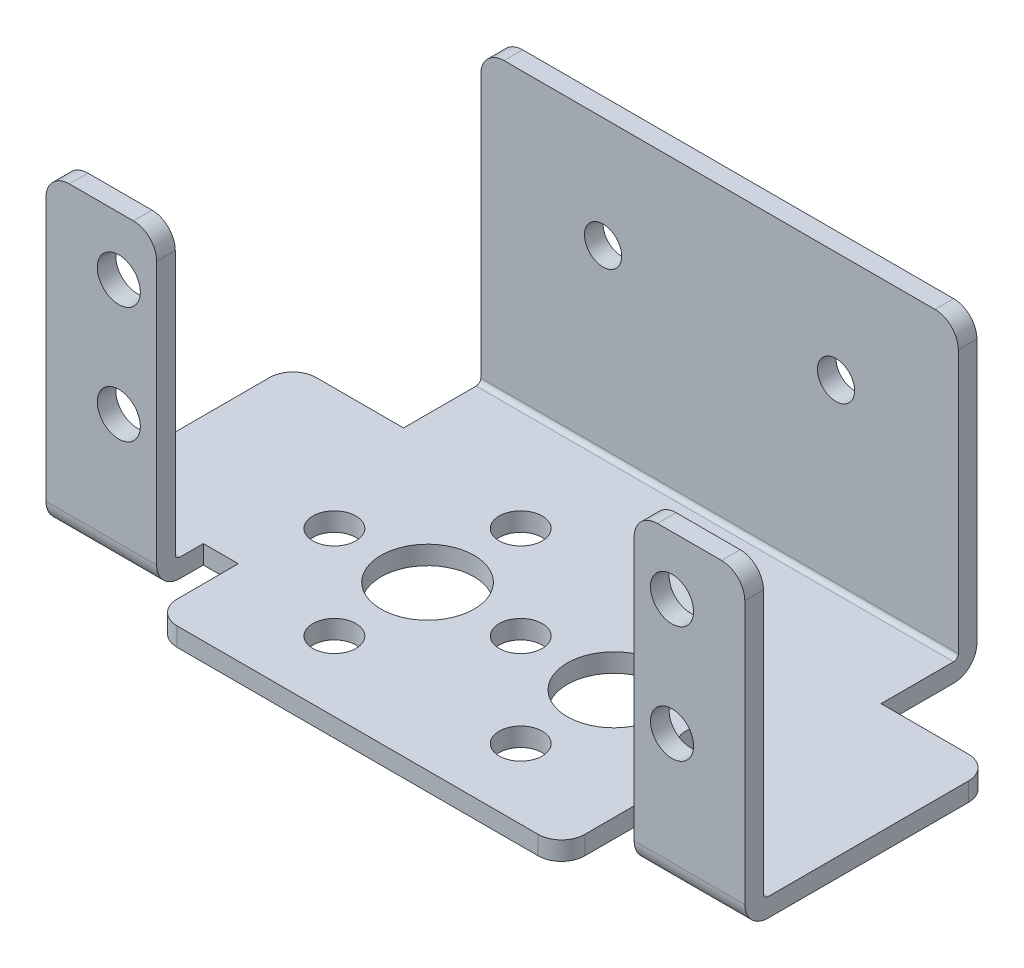
from build123d import *

# Parameters (mm, degrees)
SKETCH1_W                      = 26.6
SKETCH1_H                      = 29.43
BOSS_EXTRUDE1_DEPTH            = 9.5
SKETCH2_W                      = 27.83
SKETCH2_H                      = 25
CUT_EXTRUDE1_DEPTH             = 10.5
SKETCH3_W                      = 25.42
SKETCH3_H                      = 1.6
BOSS_EXTRUDE2_DEPTH            = 50.5
SKETCH4_W                      = 9.5
SKETCH4_H                      = 1.6
BOSS_EXTRUDE3_DEPTH            = 4.01
SKETCH5_W                      = 9.5
SKETCH5_H                      = 1.6
BOSS_EXTRUDE4_DEPTH            = 25
SKETCH6_W                      = 9.5
SKETCH6_H                      = 8.23
CUT_EXTRUDE2_DEPTH             = 2.6
SKETCH7_W                      = 9.5
SKETCH7_H                      = 8.23
CUT_EXTRUDE3_DEPTH             = 2.6
SKETCH8_W                      = 41
SKETCH8_H                      = 1.6
BOSS_EXTRUDE5_DEPTH            = 25
SKETCH9_W                      = 35
SKETCH9_H                      = 1.6
BOSS_EXTRUDE6_DEPTH            = 7.25
F_3_7_3_7_DIAMETER_HOLE1_D     = 3.7
F_3_7_3_7_DIAMETER_HOLE1_DEPTH = 26.6
F_8_0_8_DIAMETER_HOLE1_D       = 8
F_8_0_8_DIAMETER_HOLE1_DEPTH   = 26.6
F_3_2_3_2_DIAMETER_HOLE1_D     = 3.2
F_3_2_3_2_DIAMETER_HOLE1_DEPTH = 32.67
F_3_7_3_7_DIAMETER_HOLE2_D     = 3.7
F_3_7_3_7_DIAMETER_HOLE2_DEPTH = 29.43
FILLET1_R                      = 0.4
FILLET2_R                      = 2


with BuildPart() as part:
    # Sketch1 → Boss-Extrude1 (new body)
    with BuildSketch(Plane(origin=(-30, 0, 0), x_dir=(0, -1, 0), z_dir=(-1, 0, 0))):
        with Locations((-13.3, -3.955)):
            Rectangle(SKETCH1_W, SKETCH1_H)
    extrude(amount=-BOSS_EXTRUDE1_DEPTH)

    # Sketch2 → Cut-Extrude1 (cut, through all)
    with BuildSketch(Plane(origin=(-20.5, 0, 0), x_dir=(0, 0, -1), z_dir=(1, 0, 0))):
        with Locations((4.755, 14.1)):
            Rectangle(SKETCH2_W, SKETCH2_H)
    extrude(amount=-CUT_EXTRUDE1_DEPTH, mode=Mode.SUBTRACT)

    # Sketch3 → Boss-Extrude2 (add)
    with BuildSketch(Plane(origin=(-20.5, 0, 0), x_dir=(0, 0, -1), z_dir=(1, 0, 0))):
        with Locations((5.96, 0.8)):
            Rectangle(SKETCH3_W, SKETCH3_H)
    extrude(amount=BOSS_EXTRUDE2_DEPTH)

    # Sketch4 → Boss-Extrude3 (add)
    with BuildSketch(Plane.XY.offset(6.75)):
        with Locations((25.25, 0.8)):
            Rectangle(SKETCH4_W, SKETCH4_H)
    extrude(amount=BOSS_EXTRUDE3_DEPTH)

    # Sketch5 → Boss-Extrude4 (add)
    with BuildSketch(Plane(origin=(0, 1.6, 0), x_dir=(-1, 0, 0), z_dir=(0, 1, 0))):
        with Locations((-25.25, 9.96)):
            Rectangle(SKETCH5_W, SKETCH5_H)
    extrude(amount=BOSS_EXTRUDE4_DEPTH)

    # Sketch6 → Cut-Extrude2 (cut, through all)
    with BuildSketch(Plane(origin=(0, 1.6, 0), x_dir=(-1, 0, 0), z_dir=(0, 1, 0))):
        with Locations((25.25, -14.555)):
            Rectangle(SKETCH6_W, SKETCH6_H)
    extrude(amount=-CUT_EXTRUDE2_DEPTH, mode=Mode.SUBTRACT)

    # Sketch7 → Cut-Extrude3 (cut, through all)
    with BuildSketch(Plane(origin=(0, 1.6, 0), x_dir=(-1, 0, 0), z_dir=(0, 1, 0))):
        with Locations((-25.25, -14.555)):
            Rectangle(SKETCH7_W, SKETCH7_H)
    extrude(amount=-CUT_EXTRUDE3_DEPTH, mode=Mode.SUBTRACT)

    # Sketch8 → Boss-Extrude5 (add)
    with BuildSketch(Plane(origin=(0, 1.6, 0), x_dir=(-1, 0, 0), z_dir=(0, 1, 0))):
        with Locations((0, -17.87)):
            Rectangle(SKETCH8_W, SKETCH8_H)
    extrude(amount=BOSS_EXTRUDE5_DEPTH)

    # Sketch9 → Boss-Extrude6 (add)
    with BuildSketch(Plane.XY.offset(6.75)):
        with Locations((0, 0.8)):
            Rectangle(SKETCH9_W, SKETCH9_H)
    extrude(amount=BOSS_EXTRUDE6_DEPTH)

    # Ø3.7 (3.7) Diameter Hole1
    with Locations(Plane(origin=(0, 0, 0), x_dir=(-1, 0, 0), z_dir=(0, -1, 0))):
        with Locations((-16, 0), (-8, 8), (-8, -8), (16, 0), (8, 8), (8, -8), (0, 0)):
            Hole(F_3_7_3_7_DIAMETER_HOLE1_D / 2, depth=F_3_7_3_7_DIAMETER_HOLE1_DEPTH)

    # Ø8.0 (8) Diameter Hole1
    with Locations(Plane(origin=(0, 0, 0), x_dir=(-1, 0, 0), z_dir=(0, -1, 0))):
        with Locations((-8, 0), (8, 0)):
            Hole(F_8_0_8_DIAMETER_HOLE1_D / 2, depth=F_8_0_8_DIAMETER_HOLE1_DEPTH)

    # Ø3.2 (3.2) Diameter Hole1
    with Locations(Plane(origin=(0, 0, -18.67), x_dir=(-1, 0, 0), z_dir=(0, 0, -1))):
        with Locations((-10, 17.1), (10, 17.1)):
            Hole(F_3_2_3_2_DIAMETER_HOLE1_D / 2, depth=F_3_2_3_2_DIAMETER_HOLE1_DEPTH)

    # Ø3.7 (3.7) Diameter Hole2
    with Locations(Plane.XY.offset(10.76)):
        with Locations((-23.75, 11.6), (-23.75, 21.6), (23.75, 11.6), (23.75, 21.6)):
            Hole(F_3_7_3_7_DIAMETER_HOLE2_D / 2, depth=F_3_7_3_7_DIAMETER_HOLE2_DEPTH)

    # Fillet1
    fillet1_edges = [part.edges().sort_by_distance(p)[0] for p in [
        (0, 1.6, -17.07),
        (-25.25, 1.6, 9.16),
        (25.25, 1.6, 9.16),
    ]]
    fillet(fillet1_edges, radius=FILLET1_R)

    # Fillet2
    fillet2_edges = [part.edges().sort_by_distance(p)[0] for p in [
        (20.5, 26.6, -17.87),
        (-20.5, 26.6, -17.87),
        (17.5, 0.8, 14),
        (-17.5, 0.8, 14),
        (25.25, 0, 10.76),
        (-30, 26.6, 9.96),
        (30, 26.6, 9.96),
        (20.5, 26.6, 9.96),
        (-30, 0.8, -10.44),
        (-20.5, 26.6, 9.96),
        (-25.25, 0, 10.76),
        (30, 0.8, -10.44),
        (0, 0, -18.67),
    ]]
    fillet(fillet2_edges, radius=FILLET2_R)


solid = part.part
